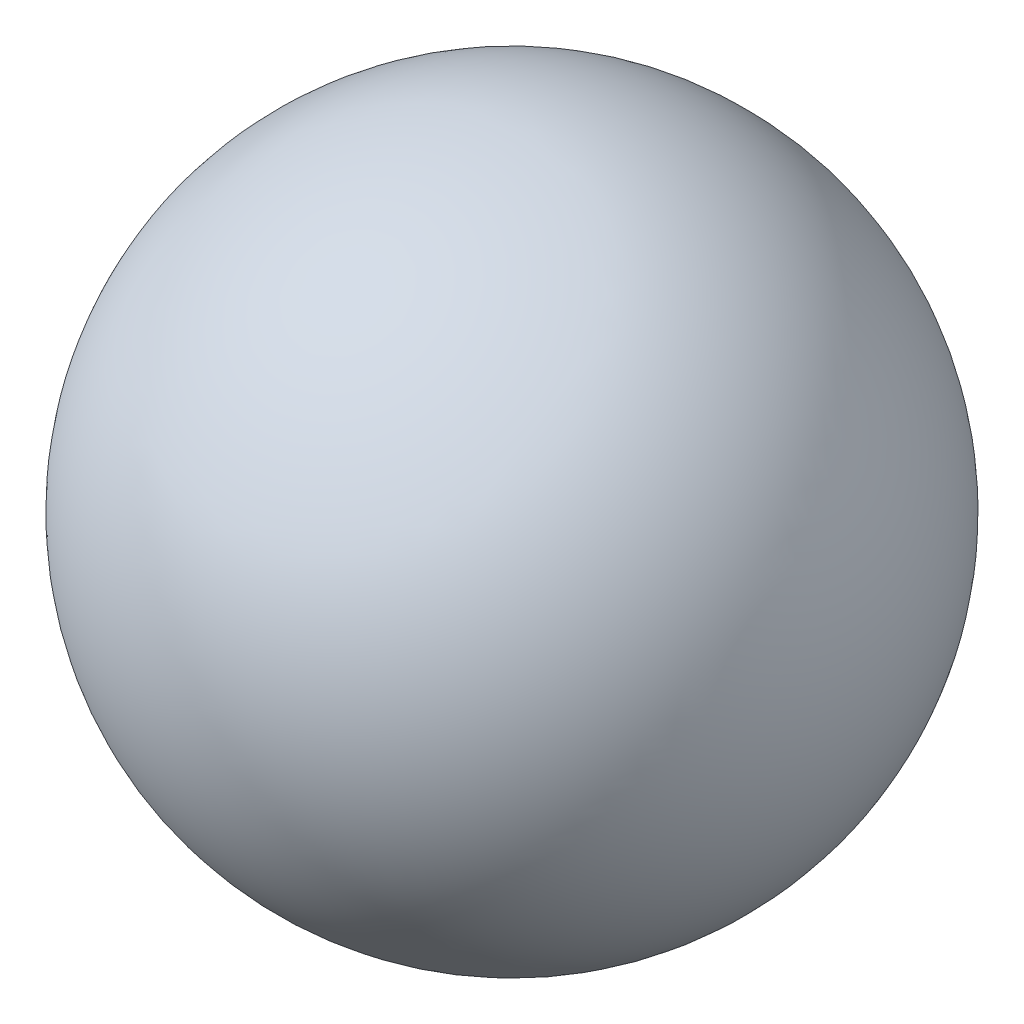
from build123d import *

# Parameters (mm, degrees)
SCALE1_SCALE = 1.2
SCALE2_SCALE = 0.1


with BuildPart() as part:
    # Sketch1 → Revolve1 (revolve)
    with BuildSketch(Plane.XY):
        with BuildLine():
            Line((-12, 0), (12, 0))
            ThreePointArc((12, 0), (0, -12), (-12, 0))
        make_face()
    revolve(axis=Axis((-12, 0, 0), (1, 0, 0)))


with BuildPart() as part_1:
    # Scale1: scaled about (0, 0, 0)
    add(part.part.scale(SCALE1_SCALE))


with BuildPart() as part_2:
    # Scale2: scaled about (0, 0, 0)
    add(part_1.part.scale(SCALE2_SCALE))


solid = part_2.part
